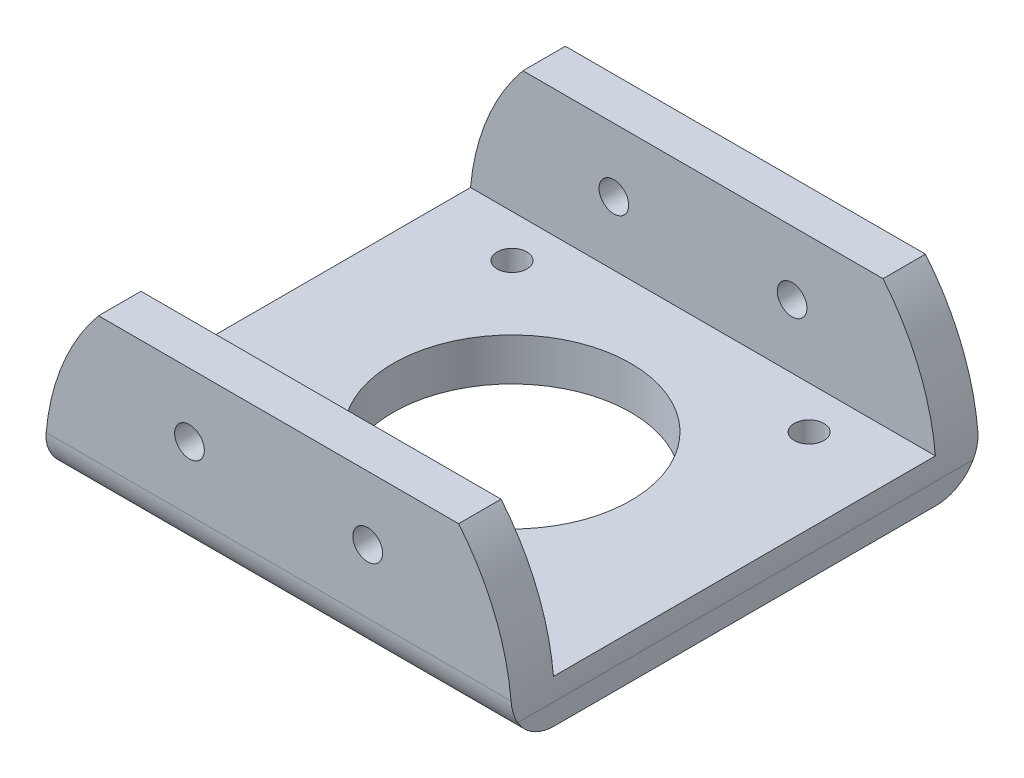
from build123d import *

# Parameters (mm, degrees)
SKETCH1_W           = 55
SKETCH1_H           = 55
BOSS_EXTRUDE1_DEPTH = 5
CUT_EXTRUDE2_REACH  = 41.211
SKETCH10_R          = 14
SKETCH10_R_2        = 1.75
SKETCH11_W          = 55
SKETCH11_H          = 5
BOSS_EXTRUDE2_DEPTH = 15
FILLET1_R           = 5
SKETCH12_R          = 1.75
CUT_EXTRUDE3_DEPTH  = 65.662585782
CUT_EXTRUDE4_DEPTH  = 65.662585782


with BuildPart() as part:
    # Sketch1 → Boss-Extrude1 (new body)
    with BuildSketch(Plane(origin=(0, 0, 0), x_dir=(1, 0, 0), z_dir=(0, 1, 0))):
        Rectangle(SKETCH1_W, SKETCH1_H)
    extrude(amount=BOSS_EXTRUDE1_DEPTH)

    # Sketch10 → Cut-Extrude2 (cut, up to next)
    with BuildSketch(Plane(origin=(0, 5, 0), x_dir=(1, 0, 0), z_dir=(0, 1, 0)), mode=Mode.PRIVATE) as cut_extrude2_sk1:
        Circle(SKETCH10_R)
    cut_extrude2_tool1 = extrude(cut_extrude2_sk1.sketch, amount=-CUT_EXTRUDE2_REACH, mode=Mode.PRIVATE) & part.part
    # Sketch10 → Cut-Extrude2 (cut, up to next)
    with BuildSketch(Plane(origin=(0, 5, 0), x_dir=(1, 0, 0), z_dir=(0, 1, 0)), mode=Mode.PRIVATE) as cut_extrude2_sk2:
        with Locations((-17.5, 17.5)):
            Circle(SKETCH10_R_2)
    cut_extrude2_tool2 = extrude(cut_extrude2_sk2.sketch, amount=-CUT_EXTRUDE2_REACH, mode=Mode.PRIVATE) & part.part
    # Sketch10 → Cut-Extrude2 (cut, up to next)
    with BuildSketch(Plane(origin=(0, 5, 0), x_dir=(1, 0, 0), z_dir=(0, 1, 0)), mode=Mode.PRIVATE) as cut_extrude2_sk3:
        with Locations((17.5, 17.5)):
            Circle(SKETCH10_R_2)
    cut_extrude2_tool3 = extrude(cut_extrude2_sk3.sketch, amount=-CUT_EXTRUDE2_REACH, mode=Mode.PRIVATE) & part.part
    # Sketch10 → Cut-Extrude2 (cut, up to next)
    with BuildSketch(Plane(origin=(0, 5, 0), x_dir=(1, 0, 0), z_dir=(0, 1, 0)), mode=Mode.PRIVATE) as cut_extrude2_sk4:
        with Locations((17.5, -17.5)):
            Circle(SKETCH10_R_2)
    cut_extrude2_tool4 = extrude(cut_extrude2_sk4.sketch, amount=-CUT_EXTRUDE2_REACH, mode=Mode.PRIVATE) & part.part
    # Sketch10 → Cut-Extrude2 (cut, up to next)
    with BuildSketch(Plane(origin=(0, 5, 0), x_dir=(1, 0, 0), z_dir=(0, 1, 0)), mode=Mode.PRIVATE) as cut_extrude2_sk5:
        with Locations((-17.5, -17.5)):
            Circle(SKETCH10_R_2)
    cut_extrude2_tool5 = extrude(cut_extrude2_sk5.sketch, amount=-CUT_EXTRUDE2_REACH, mode=Mode.PRIVATE) & part.part
    add(cut_extrude2_tool1.solids().sort_by_distance((0, 5, 0))[0], mode=Mode.SUBTRACT)
    add(cut_extrude2_tool2.solids().sort_by_distance((-17.5, 5, -17.5))[0], mode=Mode.SUBTRACT)
    add(cut_extrude2_tool3.solids().sort_by_distance((17.5, 5, -17.5))[0], mode=Mode.SUBTRACT)
    add(cut_extrude2_tool4.solids().sort_by_distance((17.5, 5, 17.5))[0], mode=Mode.SUBTRACT)
    add(cut_extrude2_tool5.solids().sort_by_distance((-17.5, 5, 17.5))[0], mode=Mode.SUBTRACT)

    # Sketch11 → Boss-Extrude2 (add)
    with BuildSketch(Plane(origin=(0, 5, 0), x_dir=(1, 0, 0), z_dir=(0, 1, 0))):
        with Locations((0, 25)):
            Rectangle(SKETCH11_W, SKETCH11_H)
        with Locations((0, -25)):
            Rectangle(SKETCH11_W, SKETCH11_H)
    extrude(amount=BOSS_EXTRUDE2_DEPTH)

    # Fillet1
    fillet1_edges = [part.edges().sort_by_distance(p)[0] for p in [
        (0, 0, -27.5),
        (0, 0, 27.5),
    ]]
    fillet(fillet1_edges, radius=FILLET1_R)

    # Sketch12 → Cut-Extrude3 (cut, through all)
    with BuildSketch(Plane(origin=(0, 0, -27.5), x_dir=(-1, 0, 0), z_dir=(0, 0, -1))):
        with Locations((-10.5, 12.5)):
            Circle(SKETCH12_R)
        with Locations((10.5, 12.5)):
            Circle(SKETCH12_R)
    extrude(amount=-CUT_EXTRUDE3_DEPTH, mode=Mode.SUBTRACT)

    # Sketch13 → Cut-Extrude4 (cut, through all)
    with BuildSketch(Plane.XY.offset(27.5)):
        with BuildLine():
            Line((-27.5, 2.5), (-27.5, 20))
            Line((-27.5, 20), (-21.213203436, 20))
            ThreePointArc((-21.213203436, 20), (-25.880621075, 11.797497123), (-27.5, 2.5))
        make_face()
        with BuildLine():
            Line((21.213203436, 20), (27.5, 20))
            Line((27.5, 20), (27.5, 2.5))
            ThreePointArc((27.5, 2.5), (25.880621075, 11.797497123), (21.213203436, 20))
        make_face()
    extrude(amount=-CUT_EXTRUDE4_DEPTH, mode=Mode.SUBTRACT)


solid = part.part
